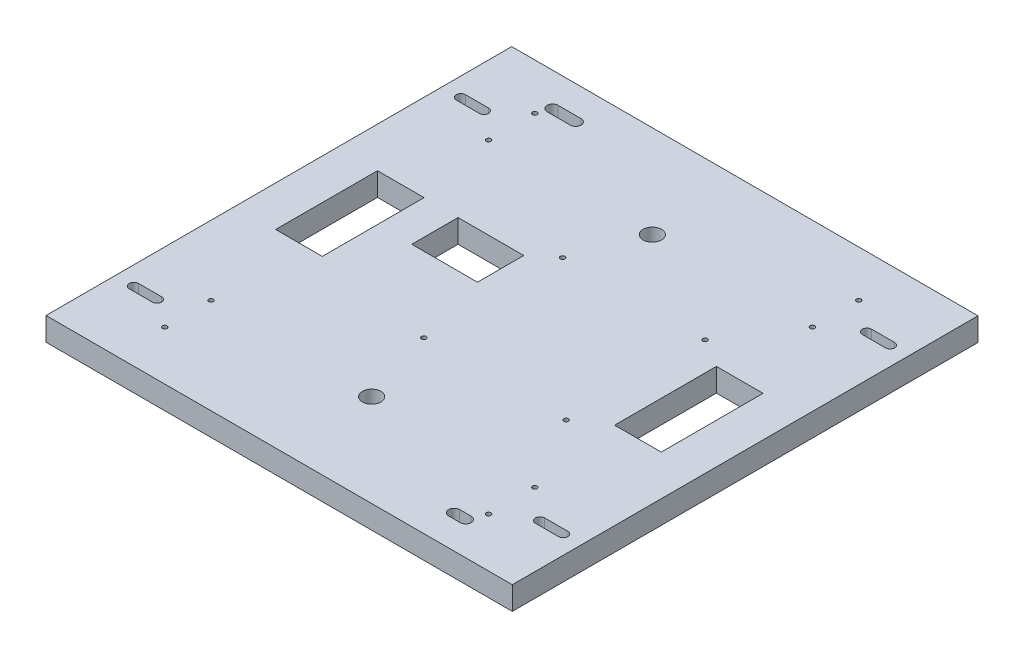
from build123d import *

# Parameters (mm, degrees)
SKETCH1_W           = 127.9906
SKETCH1_H           = 127.8382
BOSS_EXTRUDE1_DEPTH = 6.35
SKETCH3_R           = 2.54
SKETCH3_W           = 12.8016
SKETCH3_H           = 27.94
SKETCH3_W_2         = 18.034
SKETCH3_H_2         = 12.7
CUT_EXTRUDE1_DEPTH  = 7.35
SKETCH8_R           = 0.635
CUT_EXTRUDE2_DEPTH  = 20.05


with BuildPart() as part:
    # Sketch1 → Boss-Extrude1 (new body)
    with BuildSketch(Plane(origin=(0, 0, 0), x_dir=(1, 0, 0), z_dir=(0, 1, 0))):
        with Locations((63.9953, 63.9191)):
            Rectangle(SKETCH1_W, SKETCH1_H)
    extrude(amount=BOSS_EXTRUDE1_DEPTH)

    # Sketch3 → Cut-Extrude1 (cut, through all)
    with BuildSketch(Plane(origin=(0, 0, 0), x_dir=(-1, 0, 0), z_dir=(0, -1, 0))):
        with Locations((-63.9953, 25.4)):
            Circle(SKETCH3_R)
        with Locations((-63.9953, 102.4382)):
            Circle(SKETCH3_R)
        with BuildLine():
            Line((-5.08, 107.5182), (-11.43, 107.5182))
            ThreePointArc((-11.43, 107.5182), (-12.7, 108.7882), (-11.43, 110.0582))
            Line((-11.43, 110.0582), (-5.08, 110.0582))
            ThreePointArc((-5.08, 110.0582), (-3.81, 108.7882), (-5.08, 107.5182))
        make_face()
        with BuildLine():
            Line((-122.9106, 107.5182), (-116.5606, 107.5182))
            ThreePointArc((-116.5606, 107.5182), (-115.2906, 108.7882), (-116.5606, 110.0582))
            Line((-116.5606, 110.0582), (-122.9106, 110.0582))
            ThreePointArc((-122.9106, 110.0582), (-124.1806, 108.7882), (-122.9106, 107.5182))
        make_face()
        with BuildLine():
            Line((-122.9106, 20.32), (-116.5606, 20.32))
            ThreePointArc((-116.5606, 20.32), (-115.2906, 19.05), (-116.5606, 17.78))
            Line((-116.5606, 17.78), (-122.9106, 17.78))
            ThreePointArc((-122.9106, 17.78), (-124.1806, 19.05), (-122.9106, 20.32))
        make_face()
        with BuildLine():
            Line((-5.08, 20.32), (-11.43, 20.32))
            ThreePointArc((-11.43, 20.32), (-12.7, 19.05), (-11.43, 17.78))
            Line((-11.43, 17.78), (-5.08, 17.78))
            ThreePointArc((-5.08, 17.78), (-3.81, 19.05), (-5.08, 20.32))
        make_face()
        with BuildLine():
            Line((-20.32, 117.2083), (-26.67, 117.2083))
            ThreePointArc((-26.67, 117.2083), (-28.1813, 118.7196), (-26.67, 120.2309))
            Line((-26.67, 120.2309), (-20.32, 120.2309))
            ThreePointArc((-20.32, 120.2309), (-18.8087, 118.7196), (-20.32, 117.2083))
        make_face()
        with BuildLine():
            Line((-102.9081, 7.6073), (-106.0831, 7.6073))
            ThreePointArc((-106.0831, 7.6073), (-107.5944, 9.1186), (-106.0831, 10.6299))
            Line((-106.0831, 10.6299), (-102.9081, 10.6299))
            ThreePointArc((-102.9081, 10.6299), (-101.3968, 9.1186), (-102.9081, 7.6073))
        make_face()
        with Locations((-110.5154, 65.9384)):
            Rectangle(SKETCH3_W, SKETCH3_H)
        with Locations((-17.4752, 65.9384)):
            Rectangle(SKETCH3_W, SKETCH3_H)
        with Locations((-42.291, 73.4822)):
            Rectangle(SKETCH3_W_2, SKETCH3_H_2)
    extrude(amount=-CUT_EXTRUDE1_DEPTH, mode=Mode.SUBTRACT)

    # Sketch8 → Cut-Extrude2 (cut, through all)
    with BuildSketch(Plane.XZ.offset(12.7)):
        with Locations((19.05, -26.2382)):
            Circle(SKETCH8_R)
        with Locations((19.05, -13.5382)):
            Circle(SKETCH8_R)
        with Locations((19.05, -102.4382)):
            Circle(SKETCH8_R)
        with Locations((19.05, -115.1382)):
            Circle(SKETCH8_R)
        with Locations((57.15, -84.6582)):
            Circle(SKETCH8_R)
        with Locations((57.15, -46.5582)):
            Circle(SKETCH8_R)
        with Locations((96.2406, -46.5582)):
            Circle(SKETCH8_R)
        with Locations((96.2406, -84.6582)):
            Circle(SKETCH8_R)
        with Locations((107.95, -115.1382)):
            Circle(SKETCH8_R)
        with Locations((107.95, -102.4382)):
            Circle(SKETCH8_R)
        with Locations((107.95, -26.2382)):
            Circle(SKETCH8_R)
        with Locations((107.95, -13.5382)):
            Circle(SKETCH8_R)
    extrude(amount=-CUT_EXTRUDE2_DEPTH, mode=Mode.SUBTRACT)


solid = part.part
